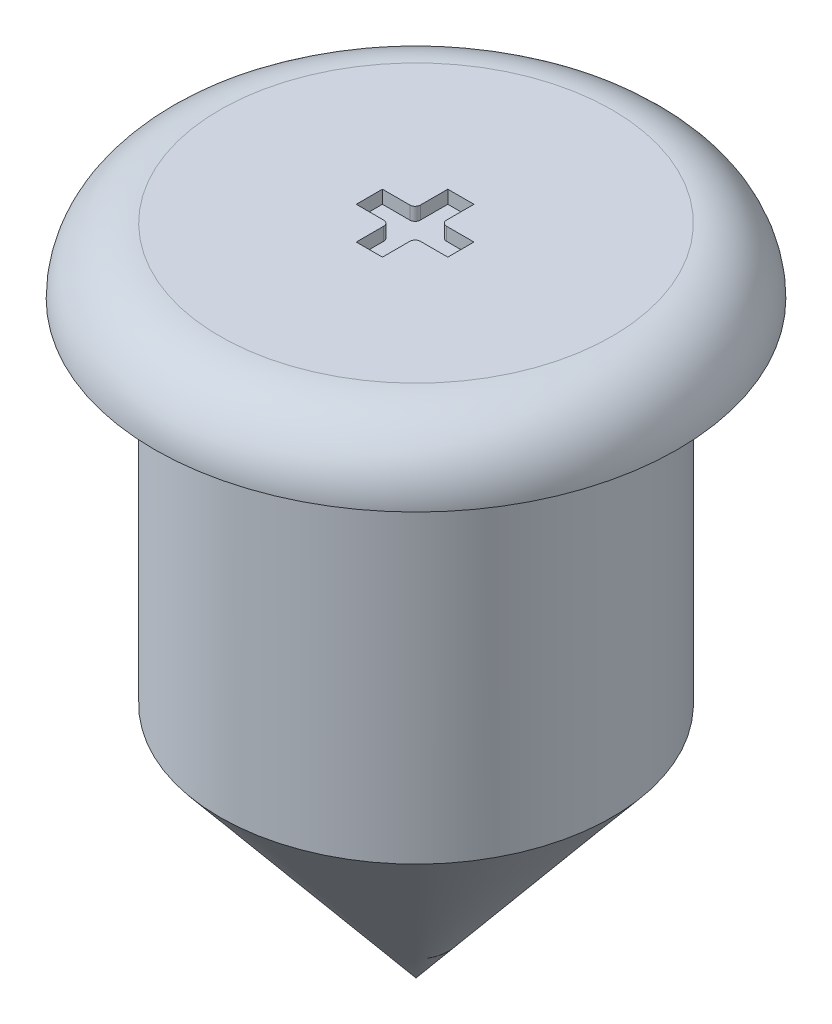
from build123d import *

# Parameters (mm, degrees)
CUT_EXTRUDE1_DEPTH = 0.1


with BuildPart() as part:
    # Sketch1 → Revolve1 (revolve)
    with BuildSketch(Plane.XY):
        with BuildLine():
            Line((0, -33.827367013), (0, -28.827367013))
            Line((0, -28.827367013), (1.5, -28.827367013))
            ThreePointArc((1.5, -28.827367013), (1.853553391, -28.973813622), (2, -29.327367013))
            Line((2, -29.327367013), (1.5, -29.327367013))
            Line((1.5, -29.327367013), (1.5, -32.013019536))
            Line((1.5, -32.013019536), (0, -33.827367013))
        make_face()
    revolve(axis=Axis((0, -33.827367013, 0), (0, 1, 0)))

    # Sketch2 → Cut-Extrude1 (cut)
    with BuildSketch(Plane(origin=(0, -28.827367013, 0), x_dir=(1, 0, 0), z_dir=(0, 1, 0))):
        with BuildLine():
            Line((-0.102740447, 0.345923698), (0.097259553, 0.345923698))
            Line((0.097259553, 0.345923698), (0.097259553, 0.135923698))
            ThreePointArc((0.097259553, 0.135923698), (0.108975282, 0.107639426), (0.137259553, 0.095923698))
            Line((0.137259553, 0.095923698), (0.347259553, 0.095923698))
            Line((0.347259553, 0.095923698), (0.347259553, -0.104076302))
            Line((0.347259553, -0.104076302), (0.137259553, -0.104076302))
            ThreePointArc((0.137259553, -0.104076302), (0.108975282, -0.115792031), (0.097259553, -0.144076302))
            Line((0.097259553, -0.144076302), (0.097259553, -0.354076302))
            Line((0.097259553, -0.354076302), (-0.102740447, -0.354076302))
            Line((-0.102740447, -0.354076302), (-0.102740447, -0.144076302))
            ThreePointArc((-0.102740447, -0.144076302), (-0.114456176, -0.115792031), (-0.142740447, -0.104076302))
            Line((-0.142740447, -0.104076302), (-0.352740447, -0.104076302))
            Line((-0.352740447, -0.104076302), (-0.352740447, 0.095923698))
            Line((-0.352740447, 0.095923698), (-0.142740447, 0.095923698))
            ThreePointArc((-0.142740447, 0.095923698), (-0.114456176, 0.107639426), (-0.102740447, 0.135923698))
            Line((-0.102740447, 0.135923698), (-0.102740447, 0.345923698))
        make_face()
    extrude(amount=-CUT_EXTRUDE1_DEPTH, mode=Mode.SUBTRACT)


solid = part.part
